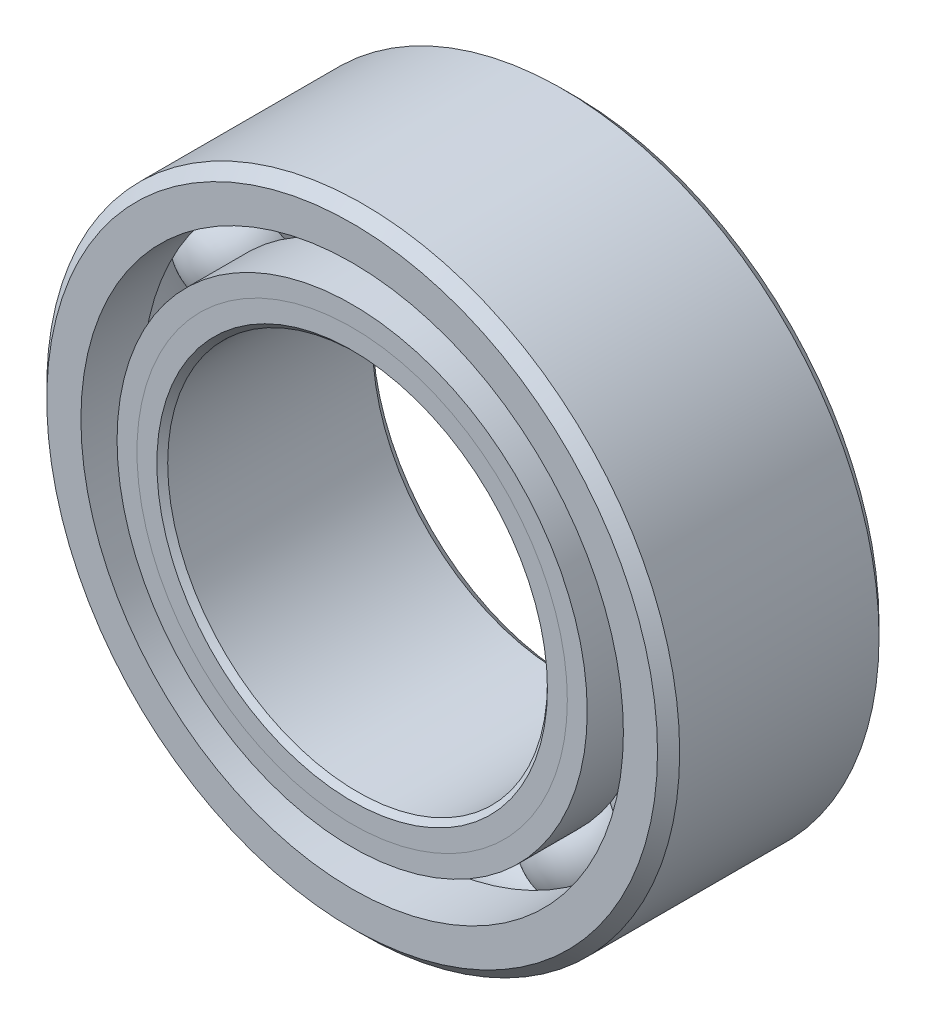
from build123d import *

# Parameters (mm, degrees)
CIRPATTERN1_COUNT = 12


with BuildPart() as part:
    # Sketch1 → Revolve1 (revolve)
    with BuildSketch(Plane(origin=(0, 0, 0), x_dir=(0, 0, -1), z_dir=(1, 0, 0))):
        with BuildLine():
            Line((1.25015625, 3.96875), (-1.25015625, 3.96875))
            Line((-1.25015625, 3.96875), (-1.3890625, 3.82984375))
            Line((-1.3890625, 3.82984375), (-1.3890625, 3.401785714))
            Line((-1.3890625, 3.401785714), (-0.617361111, 3.401785714))
            ThreePointArc((-0.617361111, 3.401785714), (0, 3.83269788), (0.617361111, 3.401785714))
            Line((0.617361111, 3.401785714), (1.3890625, 3.401785714))
            Line((1.3890625, 3.401785714), (1.3890625, 3.82984375))
            Line((1.3890625, 3.82984375), (1.25015625, 3.96875))
        make_face()
    revolve(axis=Axis((0, 0, 1.3890625), (0, 0, -1)))


with BuildPart() as body_2:
    # Sketch2 → Revolve2 (revolve)
    with BuildSketch(Plane(origin=(0, 0, 0), x_dir=(0, 0, -1), z_dir=(1, 0, 0))):
        with BuildLine():
            Line((-1.3890625, 2.948214286), (-0.617361111, 2.948214286))
            ThreePointArc((-0.617361111, 2.948214286), (-0.376437258, 2.635684237), (0, 2.51730212))
            Line((0, 2.51730212), (0, 2.44927606))
            Line((0, 2.44927606), (-1.139593387, 2.44927606))
            Line((-1.139593387, 2.44927606), (-1.3890625, 2.698745173))
            Line((-1.3890625, 2.698745173), (-1.3890625, 2.948214286))
        make_face()
    revolve(axis=Axis((0, 0, 1.3890625), (0, 0, -1)))


with BuildPart() as body_3:
    # Sketch3 → Revolve3 (revolve)
    with BuildSketch(Plane(origin=(0, 0, 0), x_dir=(0, 0, -1), z_dir=(1, 0, 0))):
        with BuildLine():
            Line((-1.3890625, 2.698745173), (-1.139593387, 2.44927606))
            Line((-1.139593387, 2.44927606), (0, 2.44927606))
            Line((0, 2.44927606), (0, 2.51730212))
            ThreePointArc((0, 2.51730212), (0.376437258, 2.635684237), (0.617361111, 2.948214286))
            Line((0.617361111, 2.948214286), (1.3890625, 2.948214286))
            Line((1.3890625, 2.948214286), (1.3890625, 2.52015625))
            Line((1.3890625, 2.52015625), (1.25015625, 2.38125))
            Line((1.25015625, 2.38125), (-1.32103644, 2.38125))
            Line((-1.32103644, 2.38125), (-1.3890625, 2.44927606))
            Line((-1.3890625, 2.44927606), (-1.3890625, 2.698745173))
        make_face()
    revolve(axis=Axis((0, 0, 1.3890625), (0, 0, -1)))


with BuildPart() as body_4:
    # Sketch4 → Revolve4 (revolve)
    with BuildSketch(Plane(origin=(0, 0, 0), x_dir=(0, 0, -1), z_dir=(1, 0, 0))):
        with BuildLine():
            Line((-0.65769788, 3.175), (0.65769788, 3.175))
            ThreePointArc((0.65769788, 3.175), (0, 3.83269788), (-0.65769788, 3.175))
        make_face()
    revolve(axis=Axis((0, 3.175, 0.65769788), (0, 0, -1)))


with BuildPart() as cirpattern1_1:
    # CirPattern1: pattern copy
    add(body_4.part.rotate(Axis((0, 0, -1.3890625), (0, 0, 1)), 1 * 360 / CIRPATTERN1_COUNT))


with BuildPart() as cirpattern1_2:
    # CirPattern1: pattern copy
    add(body_4.part.rotate(Axis((0, 0, -1.3890625), (0, 0, 1)), 2 * 360 / CIRPATTERN1_COUNT))


with BuildPart() as cirpattern1_3:
    # CirPattern1: pattern copy
    add(body_4.part.rotate(Axis((0, 0, -1.3890625), (0, 0, 1)), 3 * 360 / CIRPATTERN1_COUNT))


with BuildPart() as cirpattern1_4:
    # CirPattern1: pattern copy
    add(body_4.part.rotate(Axis((0, 0, -1.3890625), (0, 0, 1)), 4 * 360 / CIRPATTERN1_COUNT))


with BuildPart() as cirpattern1_5:
    # CirPattern1: pattern copy
    add(body_4.part.rotate(Axis((0, 0, -1.3890625), (0, 0, 1)), 5 * 360 / CIRPATTERN1_COUNT))


with BuildPart() as cirpattern1_6:
    # CirPattern1: pattern copy
    add(body_4.part.rotate(Axis((0, 0, -1.3890625), (0, 0, 1)), 6 * 360 / CIRPATTERN1_COUNT))


with BuildPart() as cirpattern1_7:
    # CirPattern1: pattern copy
    add(body_4.part.rotate(Axis((0, 0, -1.3890625), (0, 0, 1)), 7 * 360 / CIRPATTERN1_COUNT))


with BuildPart() as cirpattern1_8:
    # CirPattern1: pattern copy
    add(body_4.part.rotate(Axis((0, 0, -1.3890625), (0, 0, 1)), 8 * 360 / CIRPATTERN1_COUNT))


with BuildPart() as cirpattern1_9:
    # CirPattern1: pattern copy
    add(body_4.part.rotate(Axis((0, 0, -1.3890625), (0, 0, 1)), 9 * 360 / CIRPATTERN1_COUNT))


with BuildPart() as cirpattern1_10:
    # CirPattern1: pattern copy
    add(body_4.part.rotate(Axis((0, 0, -1.3890625), (0, 0, 1)), 10 * 360 / CIRPATTERN1_COUNT))


with BuildPart() as cirpattern1_11:
    # CirPattern1: pattern copy
    add(body_4.part.rotate(Axis((0, 0, -1.3890625), (0, 0, 1)), 11 * 360 / CIRPATTERN1_COUNT))


solid = Compound([part.part, body_2.part, body_3.part, body_4.part, cirpattern1_1.part, cirpattern1_2.part, cirpattern1_3.part, cirpattern1_4.part, cirpattern1_5.part, cirpattern1_6.part, cirpattern1_7.part, cirpattern1_8.part, cirpattern1_9.part, cirpattern1_10.part, cirpattern1_11.part])
